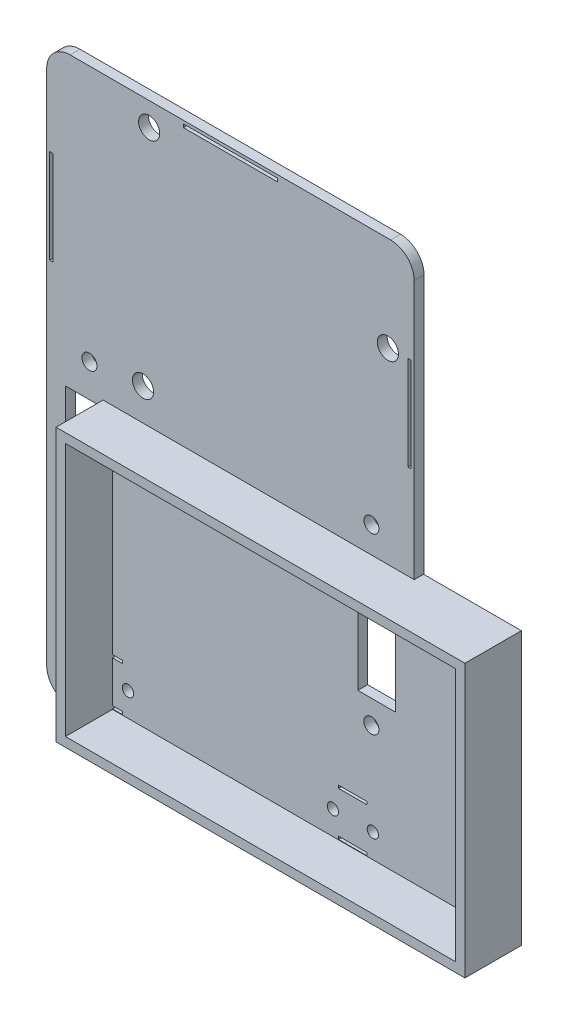
from build123d import *

# Parameters (mm, degrees)
SKETCH1_W                    = 78.2
SKETCH1_H                    = 120
SKETCH1_R                    = 2.25
BOSS_EXTRUDE1_DEPTH          = 2.1
CUT_EXTRUDE1_REACH           = 4.1
SKETCH2_R                    = 1.2
SKETCH2_W                    = 6.1
SKETCH2_H                    = 0.6
CUT_EXTRUDE3_REACH           = 4.1
SKETCH8_R                    = 1.6
SKETCH8_W                    = 8
SKETCH8_H                    = 25
FILLET2_R                    = 5
SCHIZZO2_W                   = 87
SCHIZZO2_H                   = 58
SCHIZZO2_W_2                 = 83
SCHIZZO2_H_2                 = 54
ESTRUSIONE_ESTRUSIONE1_DEPTH = 10
SCHIZZO3_W                   = 0.7
SCHIZZO3_H                   = 20
SCHIZZO3_W_2                 = 20
SCHIZZO3_H_2                 = 0.7
SCHIZZO3_H_3                 = 0.65
TAGLIO_ESTRUSIONE1_DEPTH     = 1
SCHIZZO2_3_W                 = 8
SCHIZZO2_3_H                 = 0.6
SCHIZZO2_3_W_2               = 2
ESTRUSIONE_ESTRUSIONE2_DEPTH = 2


with BuildPart() as part:
    # Sketch1 → Boss-Extrude1 (new body)
    with BuildSketch(Plane.XY):
        Rectangle(SKETCH1_W, SKETCH1_H)
        with Locations((-17.3, 55)):
            Circle(SKETCH1_R, mode=Mode.SUBTRACT)
        with Locations((33.5, 39.76)):
            Circle(SKETCH1_R, mode=Mode.SUBTRACT)
        with Locations((-18.6, 6.74)):
            Circle(SKETCH1_R, mode=Mode.SUBTRACT)
    extrude(amount=BOSS_EXTRUDE1_DEPTH)

    # Sketch2 → Cut-Extrude1 (cut, up to next)
    with BuildSketch(Plane.XY.offset(2.1), mode=Mode.PRIVATE) as cut_extrude1_sk1:
        with Locations((-30.3, -51)):
            Circle(SKETCH2_R)
    cut_extrude1_tool1 = extrude(cut_extrude1_sk1.sketch, amount=-CUT_EXTRUDE1_REACH, mode=Mode.PRIVATE) & part.part
    add(cut_extrude1_tool1.solids().sort_by_distance((-30.3, -51, 2.1))[0], mode=Mode.SUBTRACT)
    # Sketch2 → Cut-Extrude1 (cut, up to next)
    with BuildSketch(Plane.XY.offset(2.1), mode=Mode.PRIVATE) as cut_extrude1_sk2:
        with Locations((-21.8, -51)):
            Circle(SKETCH2_R)
    cut_extrude1_tool2 = extrude(cut_extrude1_sk2.sketch, amount=-CUT_EXTRUDE1_REACH, mode=Mode.PRIVATE) & part.part
    add(cut_extrude1_tool2.solids().sort_by_distance((-21.8, -51, 2.1))[0], mode=Mode.SUBTRACT)
    # Sketch2 → Cut-Extrude1 (cut, up to next)
    with BuildSketch(Plane.XY.offset(2.1), mode=Mode.PRIVATE) as cut_extrude1_sk3:
        with Locations((21.8, -51)):
            Circle(SKETCH2_R)
    cut_extrude1_tool3 = extrude(cut_extrude1_sk3.sketch, amount=-CUT_EXTRUDE1_REACH, mode=Mode.PRIVATE) & part.part
    add(cut_extrude1_tool3.solids().sort_by_distance((21.8, -51, 2.1))[0], mode=Mode.SUBTRACT)
    # Sketch2 → Cut-Extrude1 (cut, up to next)
    with BuildSketch(Plane.XY.offset(2.1), mode=Mode.PRIVATE) as cut_extrude1_sk4:
        with Locations((30.3, -51)):
            Circle(SKETCH2_R)
    cut_extrude1_tool4 = extrude(cut_extrude1_sk4.sketch, amount=-CUT_EXTRUDE1_REACH, mode=Mode.PRIVATE) & part.part
    add(cut_extrude1_tool4.solids().sort_by_distance((30.3, -51, 2.1))[0], mode=Mode.SUBTRACT)
    # Sketch2 → Cut-Extrude1 (cut, up to next)
    with BuildSketch(Plane.XY.offset(2.1), mode=Mode.PRIVATE) as cut_extrude1_sk5:
        with Locations((-26.05, -46.3)):
            Rectangle(SKETCH2_W, SKETCH2_H)
    cut_extrude1_tool5 = extrude(cut_extrude1_sk5.sketch, amount=-CUT_EXTRUDE1_REACH, mode=Mode.PRIVATE) & part.part
    add(cut_extrude1_tool5.solids().sort_by_distance((-26.05, -46.3, 2.1))[0], mode=Mode.SUBTRACT)
    # Sketch2 → Cut-Extrude1 (cut, up to next)
    with BuildSketch(Plane.XY.offset(2.1), mode=Mode.PRIVATE) as cut_extrude1_sk6:
        with Locations((-26.05, -55.7)):
            Rectangle(SKETCH2_W, SKETCH2_H)
    cut_extrude1_tool6 = extrude(cut_extrude1_sk6.sketch, amount=-CUT_EXTRUDE1_REACH, mode=Mode.PRIVATE) & part.part
    add(cut_extrude1_tool6.solids().sort_by_distance((-26.05, -55.7, 2.1))[0], mode=Mode.SUBTRACT)
    # Sketch2 → Cut-Extrude1 (cut, up to next)
    with BuildSketch(Plane.XY.offset(2.1), mode=Mode.PRIVATE) as cut_extrude1_sk7:
        with Locations((26.05, -55.7)):
            Rectangle(SKETCH2_W, SKETCH2_H)
    cut_extrude1_tool7 = extrude(cut_extrude1_sk7.sketch, amount=-CUT_EXTRUDE1_REACH, mode=Mode.PRIVATE) & part.part
    add(cut_extrude1_tool7.solids().sort_by_distance((26.05, -55.7, 2.1))[0], mode=Mode.SUBTRACT)
    # Sketch2 → Cut-Extrude1 (cut, up to next)
    with BuildSketch(Plane.XY.offset(2.1), mode=Mode.PRIVATE) as cut_extrude1_sk8:
        with Locations((26.05, -46.3)):
            Rectangle(SKETCH2_W, SKETCH2_H)
    cut_extrude1_tool8 = extrude(cut_extrude1_sk8.sketch, amount=-CUT_EXTRUDE1_REACH, mode=Mode.PRIVATE) & part.part
    add(cut_extrude1_tool8.solids().sort_by_distance((26.05, -46.3, 2.1))[0], mode=Mode.SUBTRACT)

    # Sketch8 → Cut-Extrude3 (cut, up to next)
    with BuildSketch(Plane.XY.offset(2.1), mode=Mode.PRIVATE) as cut_extrude3_sk1:
        with Locations((-30, -31.5)):
            Circle(SKETCH8_R)
    cut_extrude3_tool1 = extrude(cut_extrude3_sk1.sketch, amount=-CUT_EXTRUDE3_REACH, mode=Mode.PRIVATE) & part.part
    add(cut_extrude3_tool1.solids().sort_by_distance((-30, -31.5, 2.1))[0], mode=Mode.SUBTRACT)
    # Sketch8 → Cut-Extrude3 (cut, up to next)
    with BuildSketch(Plane.XY.offset(2.1), mode=Mode.PRIVATE) as cut_extrude3_sk2:
        with Locations((30, -31.5)):
            Circle(SKETCH8_R)
    cut_extrude3_tool2 = extrude(cut_extrude3_sk2.sketch, amount=-CUT_EXTRUDE3_REACH, mode=Mode.PRIVATE) & part.part
    add(cut_extrude3_tool2.solids().sort_by_distance((30, -31.5, 2.1))[0], mode=Mode.SUBTRACT)
    # Sketch8 → Cut-Extrude3 (cut, up to next)
    with BuildSketch(Plane.XY.offset(2.1), mode=Mode.PRIVATE) as cut_extrude3_sk3:
        with Locations((30, 5.5)):
            Circle(SKETCH8_R)
    cut_extrude3_tool3 = extrude(cut_extrude3_sk3.sketch, amount=-CUT_EXTRUDE3_REACH, mode=Mode.PRIVATE) & part.part
    add(cut_extrude3_tool3.solids().sort_by_distance((30, 5.5, 2.1))[0], mode=Mode.SUBTRACT)
    # Sketch8 → Cut-Extrude3 (cut, up to next)
    with BuildSketch(Plane.XY.offset(2.1), mode=Mode.PRIVATE) as cut_extrude3_sk4:
        with Locations((-30, 5.5)):
            Circle(SKETCH8_R)
    cut_extrude3_tool4 = extrude(cut_extrude3_sk4.sketch, amount=-CUT_EXTRUDE3_REACH, mode=Mode.PRIVATE) & part.part
    add(cut_extrude3_tool4.solids().sort_by_distance((-30, 5.5, 2.1))[0], mode=Mode.SUBTRACT)
    # Sketch8 → Cut-Extrude3 (cut, up to next)
    with BuildSketch(Plane.XY.offset(2.1), mode=Mode.PRIVATE) as cut_extrude3_sk5:
        with Locations((-31.1, -14)):
            Rectangle(SKETCH8_W, SKETCH8_H)
    cut_extrude3_tool5 = extrude(cut_extrude3_sk5.sketch, amount=-CUT_EXTRUDE3_REACH, mode=Mode.PRIVATE) & part.part
    add(cut_extrude3_tool5.solids().sort_by_distance((-31.1, -14, 2.1))[0], mode=Mode.SUBTRACT)
    # Sketch8 → Cut-Extrude3 (cut, up to next)
    with BuildSketch(Plane.XY.offset(2.1), mode=Mode.PRIVATE) as cut_extrude3_sk6:
        with Locations((31.1, -14)):
            Rectangle(SKETCH8_W, SKETCH8_H)
    cut_extrude3_tool6 = extrude(cut_extrude3_sk6.sketch, amount=-CUT_EXTRUDE3_REACH, mode=Mode.PRIVATE) & part.part
    add(cut_extrude3_tool6.solids().sort_by_distance((31.1, -14, 2.1))[0], mode=Mode.SUBTRACT)

    # Fillet2
    fillet2_edges = [part.edges().sort_by_distance(p)[0] for p in [
        (39.1, -60, 1.05),
        (-39.1, -60, 1.05),
        (-39.1, 60, 1.05),
        (39.1, 60, 1.05),
    ]]
    fillet(fillet2_edges, radius=FILLET2_R)

    # Schizzo2 → Estrusione-Estrusione1 (add)
    with BuildSketch(Plane.XY.offset(2.1)):
        with Locations((16.4, -29.1)):
            Rectangle(SCHIZZO2_W, SCHIZZO2_H)
        with Locations((16.4, -29.1)):
            Rectangle(SCHIZZO2_W_2, SCHIZZO2_H_2, mode=Mode.SUBTRACT)
    extrude(amount=ESTRUSIONE_ESTRUSIONE1_DEPTH)

    # Schizzo3 → Taglio-Estrusione1 (cut)
    with BuildSketch(Plane.XY.offset(2.1)):
        with Locations((-38.1, 30)):
            Rectangle(SCHIZZO3_W, SCHIZZO3_H)
        with Locations((38.1, 30)):
            Rectangle(SCHIZZO3_W, SCHIZZO3_H)
        with Locations((0, 59)):
            Rectangle(SCHIZZO3_W_2, SCHIZZO3_H_2)
        with Locations((0, -58.975)):
            Rectangle(SCHIZZO3_W_2, SCHIZZO3_H_3)
    extrude(amount=-TAGLIO_ESTRUSIONE1_DEPTH, mode=Mode.SUBTRACT)

    # Schizzo2_3 → Estrusione-Estrusione2 (add)
    with BuildSketch(Plane.XY.offset(2.1)):
        with Locations((31.1, -1.8)):
            Rectangle(SCHIZZO2_3_W, SCHIZZO2_3_H)
        with Locations((-26.1, -46.3)):
            Rectangle(SCHIZZO2_3_W_2, SCHIZZO2_3_H)
        with BuildLine():
            Line((39.1, -0.1), (39.1, -55))
            ThreePointArc((39.1, -55), (38.823084016, -56.640877015), (38.023009049, -58.1))
            Line((38.023009049, -58.1), (59.9, -58.1))
            Line((59.9, -58.1), (59.9, -0.1))
            Line((59.9, -0.1), (39.1, -0.1))
        make_face()
        with Locations((-26.1, -55.7)):
            Rectangle(SCHIZZO2_3_W_2, SCHIZZO2_3_H)
    extrude(amount=-ESTRUSIONE_ESTRUSIONE2_DEPTH)


solid = part.part
